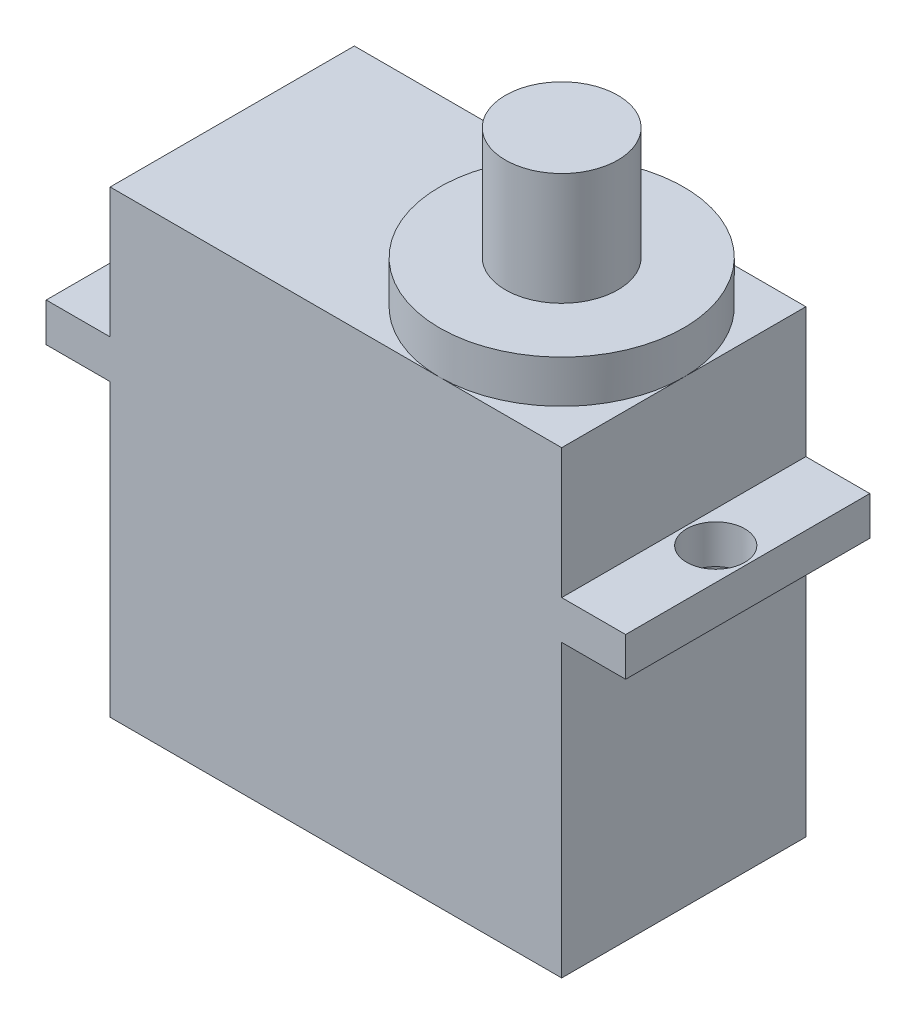
from build123d import *

# Parameters (mm, degrees)
EXTRUDE_1_DEPTH     = 6.3
SKETCH_2_R          = 6.3
SKETCH_2_R_2        = 2.9
EXTRUDE_2_DEPTH     = 2.2
EXTRUDE_START       = 2.2
SKETCH_2_3_R        = 2.9
EXTRUDE_3_DEPTH     = 5.8
SKETCH_3_R          = 1.5
CUT_EXTRUDE_1_DEPTH = 5.8


with BuildPart() as part:
    # Эскиз1 → Бобышка-Вытянуть1 (new, symmetric)
    with BuildSketch(Plane.XY):
        Polygon((-11.65, -11.85), (11.65, -11.85), (11.65, 3.15), (14.95, 3.15), (14.95, 5.15), (11.65, 5.15), (11.65, 11.85), (-11.65, 11.85), (-11.65, 5.15), (-14.95, 5.15), (-14.95, 3.15), (-11.65, 3.15), align=None)
    extrude(amount=EXTRUDE_1_DEPTH, both=True)

    # Эскиз2 → Бобышка-Вытянуть2 (add)
    with BuildSketch(Plane(origin=(0, 11.85, 0), x_dir=(1, 0, 0), z_dir=(0, 1, 0))):
        with Locations(Location((5.35, 0, 0), (0, 0, 270))):
            Circle(SKETCH_2_R)
        with Locations((5.35, 0)):
            Circle(SKETCH_2_R_2, mode=Mode.SUBTRACT)
        with Locations((5.35, 0)):
            Circle(SKETCH_2_R_2)
    extrude(amount=EXTRUDE_2_DEPTH)

    # Эскиз2<3> → Бобышка-Вытянуть3 (add)
    with BuildSketch(Plane(origin=(0, 11.85, 0), x_dir=(1, 0, 0), z_dir=(0, 1, 0)).offset(EXTRUDE_START)):
        with Locations(Location((5.35, 0, 0), (0, 0, 180))):
            Circle(SKETCH_2_3_R)
    extrude(amount=EXTRUDE_3_DEPTH)

    # Эскиз3 → Вырез-Вытянуть1 (cut)
    with BuildSketch(Plane(origin=(0, 5.15, 0), x_dir=(1, 0, 0), z_dir=(0, 1, 0))):
        with Locations(Location((-13.3, 0, 0), (0, 0, 270))):
            Circle(SKETCH_3_R)
        with Locations(Location((13.3, 0, 0), (0, 0, 180))):
            Circle(SKETCH_3_R)
    extrude(amount=-CUT_EXTRUDE_1_DEPTH, mode=Mode.SUBTRACT)


solid = part.part
